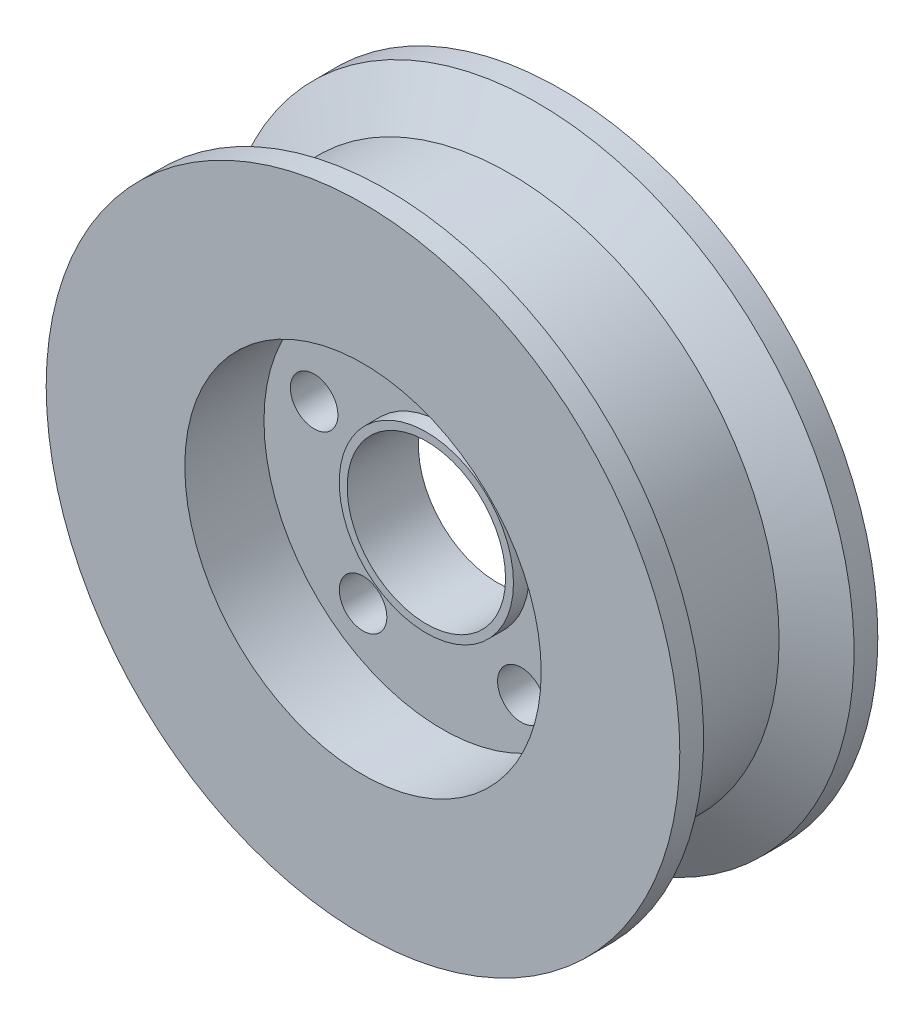
from build123d import *

# Parameters (mm, degrees)
SKETCH1_R                = 40
SKETCH1_R_2              = 10
BOSS_EXTRUDE1_DEPTH      = 12.5
SKETCH2_R                = 22.5
CUT_EXTRUDE1_DEPTH       = 10
SKETCH4_R                = 3
CUT_EXTRUDE2_DEPTH       = 16
CIRPATTERN1_COUNT        = 5
SKETCH5_R                = 11
SKETCH5_R_2              = 10
BOSS_EXTRUDE2_DEPTH      = 2
BOSS_EXTRUDE2_DEPTH_BACK = 7


with BuildPart() as part:
    # Sketch1 → Boss-Extrude1 (new body, symmetric)
    with BuildSketch(Plane.XY):
        Circle(SKETCH1_R)
        Circle(SKETCH1_R_2, mode=Mode.SUBTRACT)
    extrude(amount=BOSS_EXTRUDE1_DEPTH, both=True)

    # Sketch2 → Cut-Extrude1 (cut)
    with BuildSketch(Plane.XY.offset(12.5)):
        Circle(SKETCH2_R)
    cut_extrude1 = extrude(amount=-CUT_EXTRUDE1_DEPTH, mode=Mode.SUBTRACT)

    # Mirror1: Cut-Extrude1 across plane
    add(cut_extrude1.mirror(Plane.XY), mode=Mode.SUBTRACT)

    # Sketch4 → Cut-Extrude2 (cut, through all)
    with BuildSketch(Plane.XY.offset(2.5)):
        with Locations((0, 17)):
            Circle(SKETCH4_R)
    cut_extrude2 = extrude(amount=-CUT_EXTRUDE2_DEPTH, mode=Mode.SUBTRACT)

    # CirPattern1: Cut-Extrude2 ×5 about axis
    cirpattern1_axis = Axis((0, 0, 0), (0, 0, 1))
    for i in range(1, CIRPATTERN1_COUNT):
        add(cut_extrude2.rotate(cirpattern1_axis, i * 360 / CIRPATTERN1_COUNT), mode=Mode.SUBTRACT)

    # Sketch5 → Boss-Extrude2 (add, two sides)
    with BuildSketch(Plane.XY.offset(2.5)) as boss_extrude2_sk:
        Circle(SKETCH5_R)
        Circle(SKETCH5_R_2, mode=Mode.SUBTRACT)
    extrude(amount=BOSS_EXTRUDE2_DEPTH)
    extrude(boss_extrude2_sk.sketch, amount=-BOSS_EXTRUDE2_DEPTH_BACK)

    # Sketch6 → Cut-Revolve1 (revolve, cut)
    with BuildSketch(Plane(origin=(0, 0, 0), x_dir=(1, 0, 0), z_dir=(0, 1, 0))):
        Polygon((-40, 9.5), (-34, 6.035898385), (-34, -6.035898385), (-40, -9.5), align=None)
    revolve(axis=Axis((0, 0, -24.405777443), (0, 0, 1)), mode=Mode.SUBTRACT)


solid = part.part
